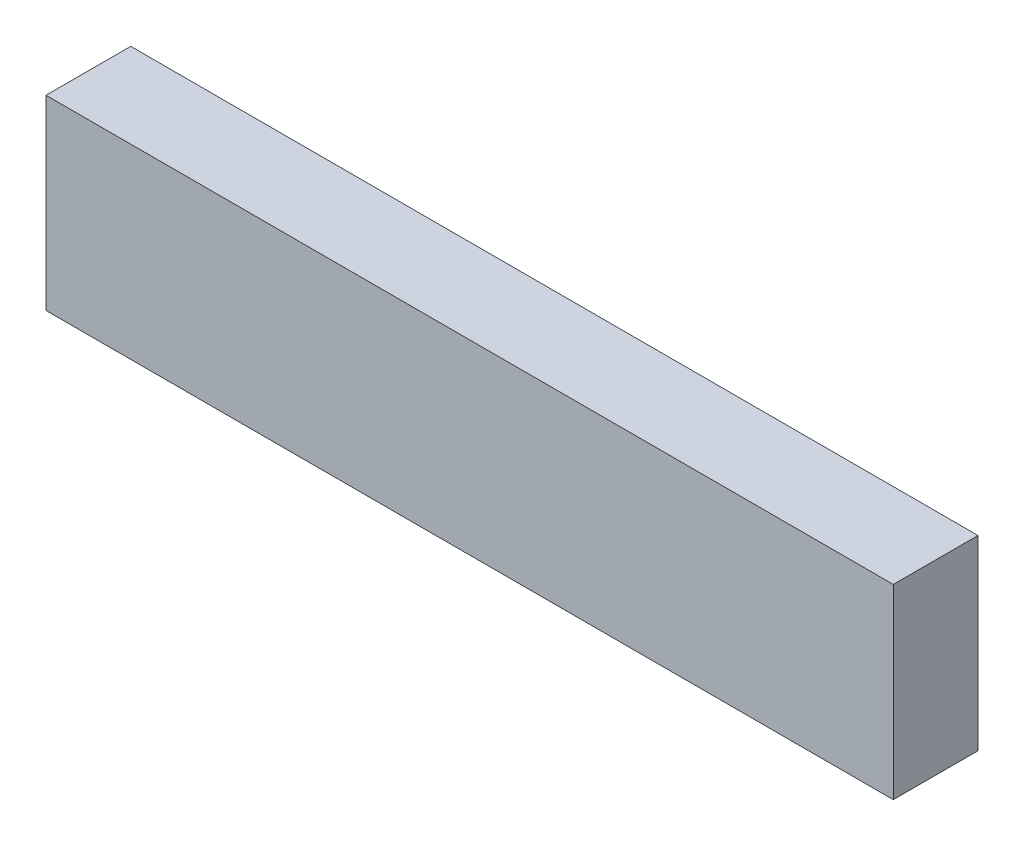
from build123d import *

# Parameters (mm, degrees)
SKETCH1_W           = 100
SKETCH1_H           = 22
BOSS_EXTRUDE1_DEPTH = 10


with BuildPart() as part:
    # Sketch1 → Boss-Extrude1 (new body)
    with BuildSketch(Plane.XY):
        with Locations((-50, 11)):
            Rectangle(SKETCH1_W, SKETCH1_H)
    extrude(amount=BOSS_EXTRUDE1_DEPTH)


solid = part.part
